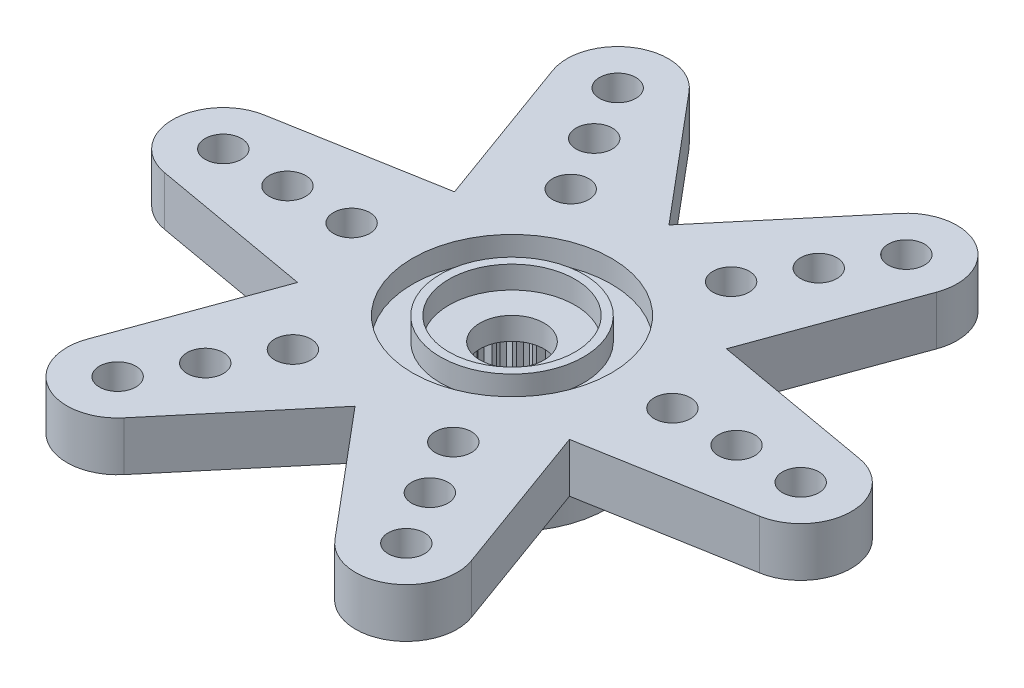
from build123d import *

# Parameters (mm, degrees)
ESQUISSE2_W                  = 4.45
ESQUISSE2_H                  = 5.6
ESQUISSE3_R                  = 0.85
BOSS_EXTRU_1_DEPTH           = 2.3
R_P_TITION_CIRCULAIRE2_COUNT = 6
ESQUISSE4_R                  = 2.95
ENL_V_MAT_EXTRU_1_DEPTH      = 1.05
ESQUISSE5_R                  = 4.65
ESQUISSE5_R_2                = 3.35
ENL_V_MAT_EXTRU_2_DEPTH      = 1.05
ESQUISSE6_R                  = 1.5
ENL_V_MAT_EXTRU_3_DEPTH      = 6.6
ESQUISSE8_R                  = 2.68
ENL_V_MAT_EXTRU_4_DEPTH      = 4.5
ENL_V_MAT_EXTRU_5_DEPTH      = 4.5
R_P_TITION_CIRCULAIRE1_COUNT = 25


with BuildPart() as part:
    # Esquisse2 → Révolution1 (revolve)
    with BuildSketch(Plane.XY):
        with Locations((-2.225, -0.7)):
            Rectangle(ESQUISSE2_W, ESQUISSE2_H)
    revolve(axis=Axis((0, 3.929571688, 0), (0, -1, 0)))

    # Esquisse3 → Boss.-Extru.1 (add)
    with BuildSketch(Plane(origin=(0, 2.1, 0), x_dir=(1, 0, 0), z_dir=(0, 1, 0))):
        with BuildLine():
            Line((-6.356626464, 3.67), (0, 3.67))
            Line((0, 3.67), (0, -3.67))
            Line((0, -3.67), (-6.356626464, -3.67))
            Line((-6.356626464, -3.67), (-13.912705307, -2.333789693))
            ThreePointArc((-13.912705307, -2.333789693), (-15.87, 0), (-13.912705307, 2.333789693))
            Line((-13.912705307, 2.333789693), (-6.356626464, 3.67))
        make_face()
        with Locations((-13.5, 0)):
            Circle(ESQUISSE3_R, mode=Mode.SUBTRACT)
        with Locations((-10.5, 0)):
            Circle(ESQUISSE3_R, mode=Mode.SUBTRACT)
        with Locations((-7.5, 0)):
            Circle(ESQUISSE3_R, mode=Mode.SUBTRACT)
    boss_extru_1 = extrude(amount=-BOSS_EXTRU_1_DEPTH)

    # Répétition circulaire2: Boss.-Extru.1 ×6 about axis
    r_p_tition_circulaire2_axis = Axis((0, 0, 0), (0, 1, 0))
    for i in range(1, R_P_TITION_CIRCULAIRE2_COUNT):
        add(boss_extru_1.rotate(r_p_tition_circulaire2_axis, i * 360 / R_P_TITION_CIRCULAIRE2_COUNT))

    # Esquisse4 → Enlèv. mat.-Extru.1 (cut)
    with BuildSketch(Plane(origin=(0, 2.1, 0), x_dir=(1, 0, 0), z_dir=(0, 1, 0))):
        Circle(ESQUISSE4_R)
    extrude(amount=-ENL_V_MAT_EXTRU_1_DEPTH, mode=Mode.SUBTRACT)

    # Esquisse5 → Enlèv. mat.-Extru.2 (cut)
    with BuildSketch(Plane(origin=(0, 2.1, 0), x_dir=(1, 0, 0), z_dir=(0, 1, 0))):
        Circle(ESQUISSE5_R)
        Circle(ESQUISSE5_R_2, mode=Mode.SUBTRACT)
    extrude(amount=-ENL_V_MAT_EXTRU_2_DEPTH, mode=Mode.SUBTRACT)

    # Esquisse6 → Enlèv. mat.-Extru.3 (cut, through all)
    with BuildSketch(Plane.XZ.offset(3.5)):
        Circle(ESQUISSE6_R)
    extrude(amount=-ENL_V_MAT_EXTRU_3_DEPTH, mode=Mode.SUBTRACT)

    # Esquisse8 → Enlèv. mat.-Extru.4 (cut, through all)
    with BuildSketch(Plane(origin=(0, 0, 0), x_dir=(1, 0, 0), z_dir=(0, 1, 0))):
        Circle(ESQUISSE8_R)
    extrude(amount=-ENL_V_MAT_EXTRU_4_DEPTH, mode=Mode.SUBTRACT)

    # Esquisse9 → Enlèv. mat.-Extru.5 (cut, through all)
    with BuildSketch(Plane(origin=(0, 0, 0), x_dir=(1, 0, 0), z_dir=(0, 1, 0))):
        with BuildLine():
            Line((0.10528472, -3.048182266), (0.265600366, -2.666806413))
            ThreePointArc((0.265600366, -2.666806413), (0, -2.68), (-0.265600366, -2.666806413))
            Line((-0.265600366, -2.666806413), (-0.10528472, -3.048182266))
            ThreePointArc((-0.10528472, -3.048182266), (0, -3.05), (0.10528472, -3.048182266))
        make_face()
    enl_v_mat_extru_5 = extrude(amount=-ENL_V_MAT_EXTRU_5_DEPTH, mode=Mode.SUBTRACT)

    # Répétition circulaire1: Enlèv. mat.-Extru.5 ×25 about axis
    r_p_tition_circulaire1_axis = Axis((0, 0, 0), (0, 1, 0))
    for i in range(1, R_P_TITION_CIRCULAIRE1_COUNT):
        add(enl_v_mat_extru_5.rotate(r_p_tition_circulaire1_axis, i * 360 / R_P_TITION_CIRCULAIRE1_COUNT), mode=Mode.SUBTRACT)


solid = part.part
